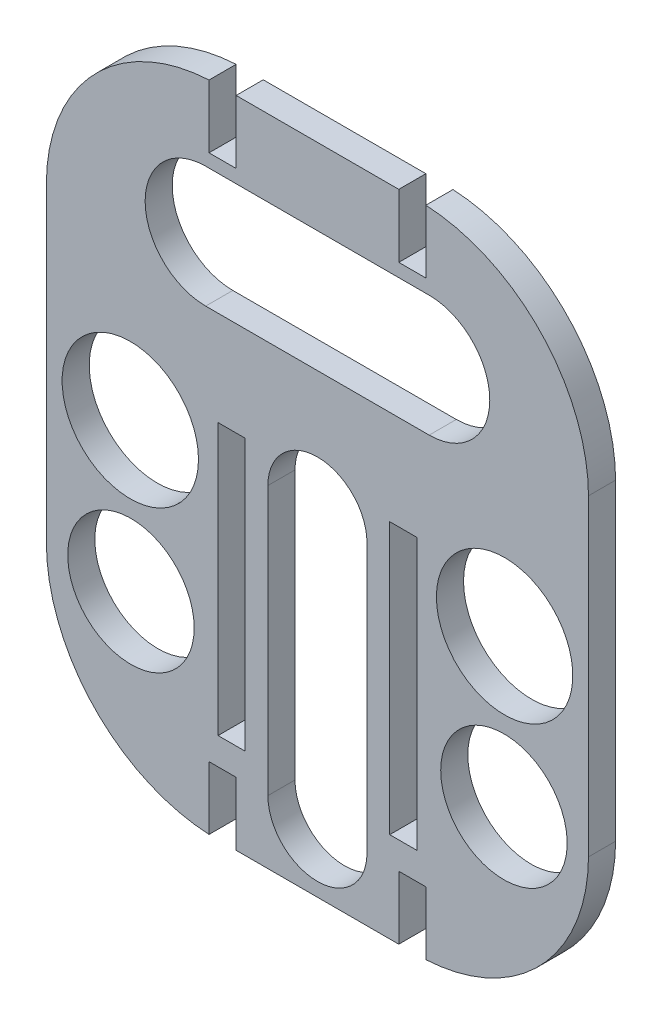
from build123d import *

# Parameters (mm, degrees)
BOSS_EXTRUDE1_DEPTH     = 3
SKETCH2_R               = 7.546344396
SKETCH2_R_2             = 6.998827146
SKETCH2_W               = 3
SKETCH2_H               = 30
SKETCH2_H_2             = 7
CUT_EXTRUDE1_DEPTH      = 1
CUT_EXTRUDE1_DEPTH_BACK = 4


with BuildPart() as part:
    # Sketch1 → Boss-Extrude1 (new body)
    with BuildSketch(Plane.XY):
        with BuildLine():
            Line((-11.521707287, -45.747254375), (11.521707287, -45.747254375))
            ThreePointArc((11.521707287, -45.747254375), (24.576520143, -40.046827338), (30, -26.874550642))
            Line((30, -26.874550642), (30, 7.734550642))
            ThreePointArc((30, 7.734550642), (24.576520143, 20.906827338), (11.521707287, 26.607254375))
            Line((11.521707287, 26.607254375), (-11.521707287, 26.607254375))
            ThreePointArc((-11.521707287, 26.607254375), (-24.576520143, 20.906827338), (-30, 7.734550642))
            Line((-30, 7.734550642), (-30, -26.874550642))
            ThreePointArc((-30, -26.874550642), (-24.576520143, -40.046827338), (-11.521707287, -45.747254375))
        make_face()
    extrude(amount=BOSS_EXTRUDE1_DEPTH)

    # Sketch2 → Cut-Extrude1 (cut, two sides)
    with BuildSketch(Plane.XY.offset(3)) as cut_extrude1_sk:
        with Locations((-20.712852781, -10.370577489)):
            Circle(SKETCH2_R)
        with Locations((-20.641158555, -26.754776444)):
            Circle(SKETCH2_R_2)
        with Locations((20.641158555, -26.754776444)):
            Circle(SKETCH2_R_2)
        with Locations((20.712852781, -10.370577489)):
            Circle(SKETCH2_R)
        with Locations((-9.5, -20.747254375)):
            Rectangle(SKETCH2_W, SKETCH2_H)
        with Locations((9.5, -20.747254375)):
            Rectangle(SKETCH2_W, SKETCH2_H)
        with BuildLine():
            Line((-12.367254006, 18.139818395), (12.367254006, 18.139818395))
            ThreePointArc((12.367254006, 18.139818395), (19.070664148, 11.436408253), (12.367254006, 4.732998111))
            Line((12.367254006, 4.732998111), (-12.367254006, 4.732998111))
            ThreePointArc((-12.367254006, 4.732998111), (-19.070664148, 11.436408253), (-12.367254006, 18.139818395))
        make_face()
        with BuildLine():
            Line((5.484608298, -9.027083299), (5.484608298, -38.747254375))
            ThreePointArc((5.484608298, -38.747254375), (0, -44.231862673), (-5.484608298, -38.747254375))
            Line((-5.484608298, -38.747254375), (-5.484608298, -9.027083299))
            ThreePointArc((-5.484608298, -9.027083299), (0, -3.542475001), (5.484608298, -9.027083299))
        make_face()
        with Locations((10.5, -42.247254375)):
            Rectangle(SKETCH2_W, SKETCH2_H_2)
        with Locations((-10.5, -42.247254375)):
            Rectangle(SKETCH2_W, SKETCH2_H_2)
        with Locations((-10.5, 23.107254375)):
            Rectangle(SKETCH2_W, SKETCH2_H_2)
        with Locations((10.5, 23.107254375)):
            Rectangle(SKETCH2_W, SKETCH2_H_2)
    extrude(amount=CUT_EXTRUDE1_DEPTH, mode=Mode.SUBTRACT)
    extrude(cut_extrude1_sk.sketch, amount=-CUT_EXTRUDE1_DEPTH_BACK, mode=Mode.SUBTRACT)


solid = part.part
